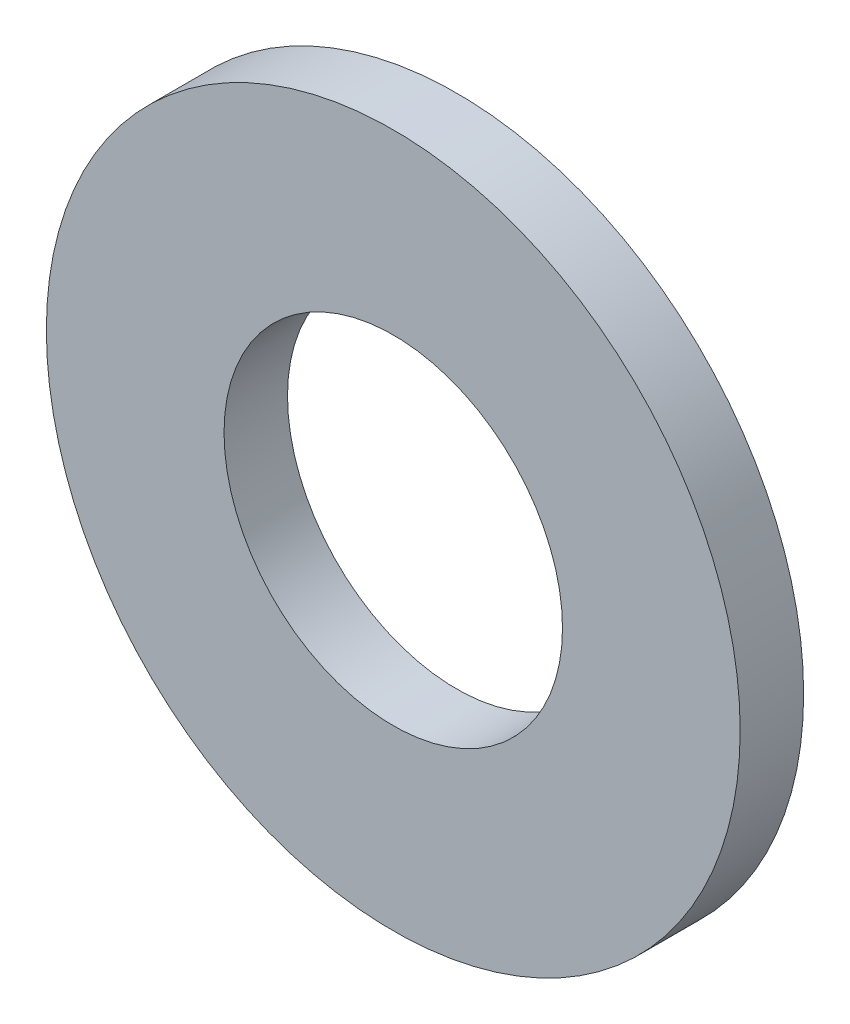
from build123d import *

# Parameters (mm, degrees)
SKETCH1_R           = 10.414
SKETCH1_R_2         = 5.08
BOSS_EXTRUDE1_DEPTH = 1.905


with BuildPart() as part:
    # Sketch1 → Boss-Extrude1 (new body)
    with BuildSketch(Plane.XY):
        Circle(SKETCH1_R)
        Circle(SKETCH1_R_2, mode=Mode.SUBTRACT)
    extrude(amount=BOSS_EXTRUDE1_DEPTH)


solid = part.part
